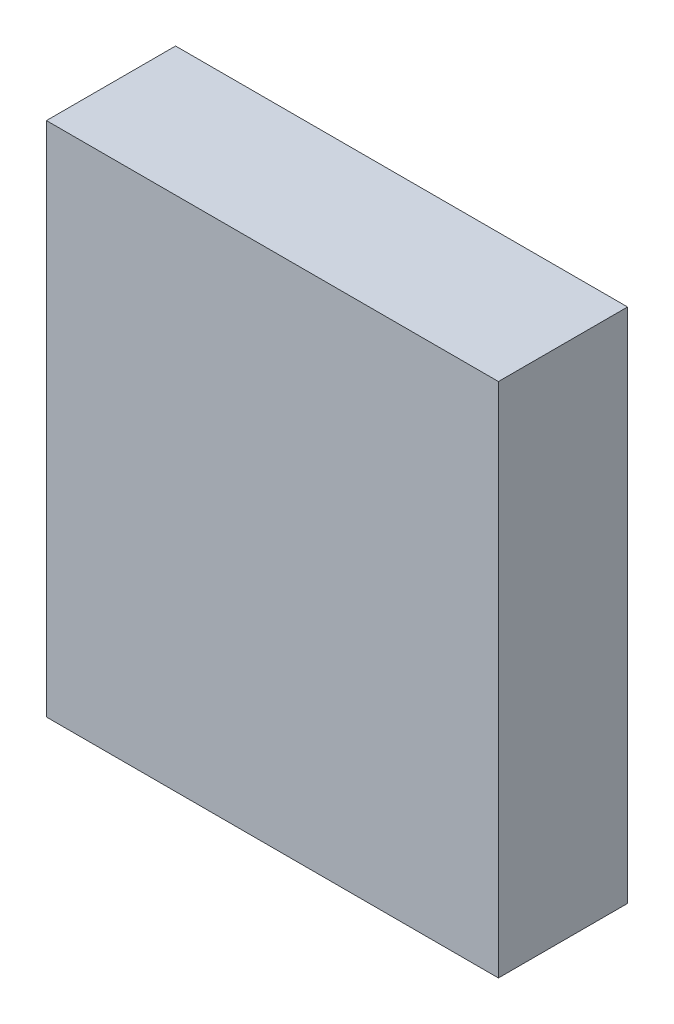
from build123d import *

# Parameters (mm, degrees)
SCHIZZO1_W                   = 35
SCHIZZO1_H                   = 40
ESTRUSIONE_ESTRUSIONE1_DEPTH = 10


with BuildPart() as part:
    # Schizzo1 → Estrusione-Estrusione1 (new body)
    with BuildSketch(Plane.XY):
        with Locations((17.5, 20)):
            Rectangle(SCHIZZO1_W, SCHIZZO1_H)
    extrude(amount=ESTRUSIONE_ESTRUSIONE1_DEPTH)


solid = part.part
